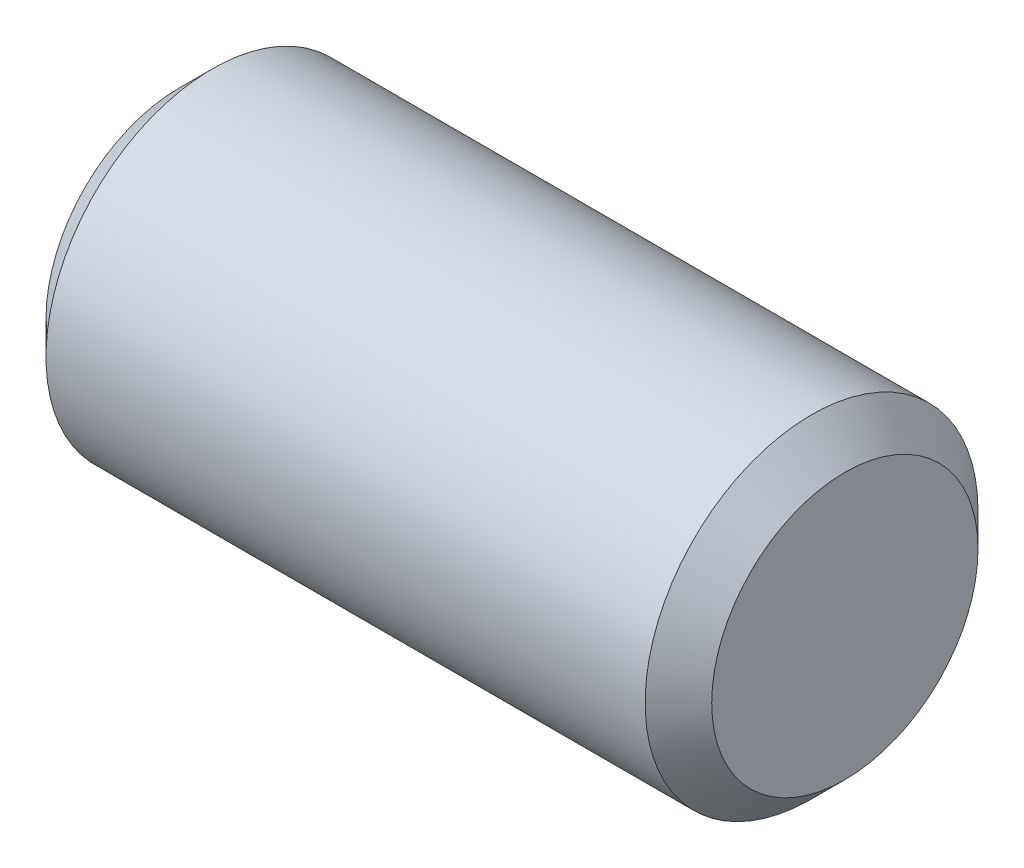
from build123d import *

# Parameters (mm, degrees)
SKETCH2_R           = 3.175
EXTRUDE1_DEPTH      = 6.35
EXTRUDE1_DEPTH_BACK = 6.35
CHAMFER1_SIZE       = 0.635


with BuildPart() as part:
    # Sketch2 → Extrude1 (new body, two sides)
    with BuildSketch(Plane(origin=(0, 0, 0), x_dir=(0, 0, -1), z_dir=(1, 0, 0))) as extrude1_sk:
        Circle(SKETCH2_R)
    extrude(amount=EXTRUDE1_DEPTH)
    extrude(extrude1_sk.sketch, amount=-EXTRUDE1_DEPTH_BACK)

    # Chamfer1
    chamfer1_edges = [part.edges().sort_by_distance(p)[0] for p in [
        (-6.35, 0, 3.175),
        (6.35, 0, 3.175),
    ]]
    chamfer(chamfer1_edges, length=CHAMFER1_SIZE)


solid = part.part
